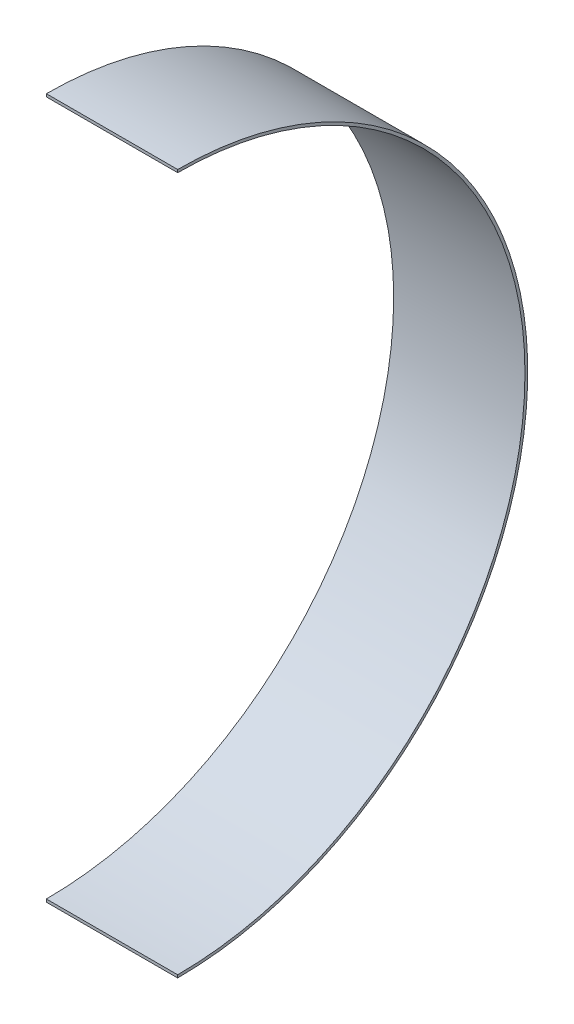
from build123d import *

# Parameters (mm, degrees)
BOSS_EXTRUDE1_DEPTH = 75


with BuildPart() as part:
    # Sketch1 → Boss-Extrude1 (new body)
    with BuildSketch(Plane(origin=(0, 0, 0), x_dir=(0, 0, -1), z_dir=(1, 0, 0))):
        with BuildLine():
            ThreePointArc((200, 0), (141.421356237, 141.421356237), (0, 200))
            Line((0, 200), (0, 198.4))
            ThreePointArc((0, 198.4), (140.289985387, 140.289985387), (198.4, 0))
            ThreePointArc((198.4, 0), (140.289985387, -140.289985387), (0, -198.4))
            Line((0, -198.4), (0, -200))
            ThreePointArc((0, -200), (141.421356237, -141.421356237), (200, 0))
        make_face()
    extrude(amount=BOSS_EXTRUDE1_DEPTH)


solid = part.part
